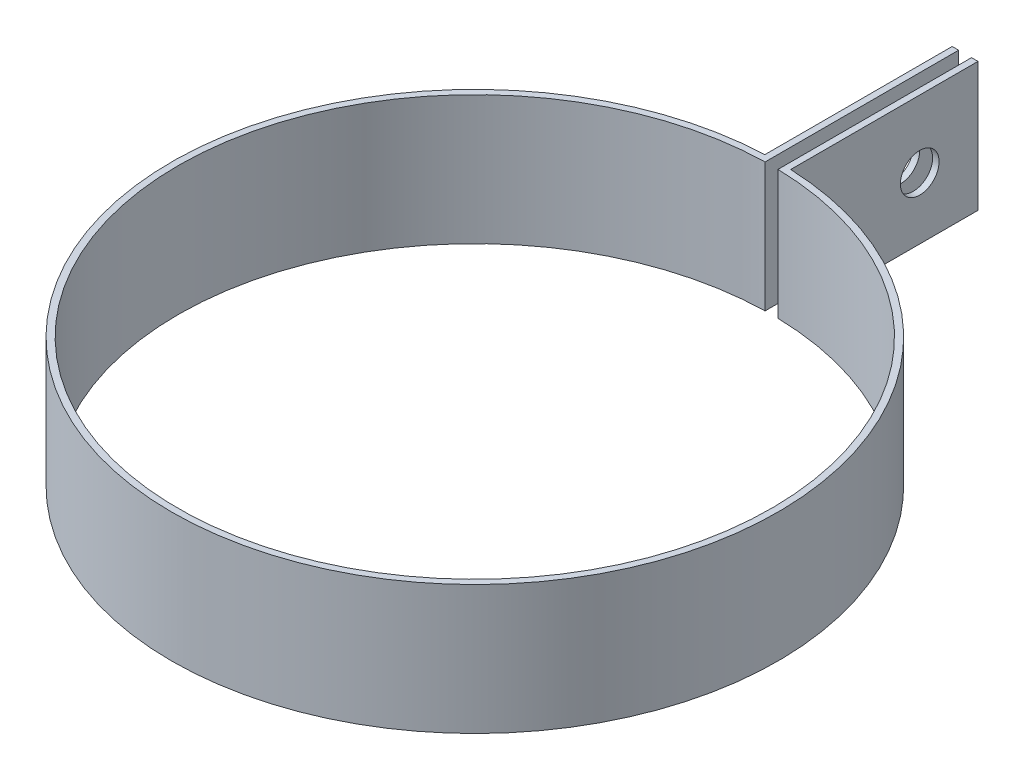
from build123d import *

# Parameters (mm, degrees)
BOSS_EXTRUDE1_DEPTH = 10
SKETCH2_R           = 1.5
CUT_EXTRUDE1_DEPTH  = 25.5


with BuildPart() as part:
    # Sketch1 → Boss-Extrude1 (new body)
    with BuildSketch(Plane(origin=(0, 0, 0), x_dir=(1, 0, 0), z_dir=(0, 1, 0))):
        with BuildLine():
            Line((-0.5, 37.994564575), (-0.5, 22.994564575))
            ThreePointArc((-0.5, 22.994564575), (0, -23), (0.5, 22.994564575))
            Line((0.5, 22.994564575), (0.5, 37.994564575))
            Line((0.5, 37.994564575), (1, 37.994564575))
            Line((1, 37.994564575), (1, 23.478713764))
            ThreePointArc((1, 23.478713764), (0, -23.5), (-1, 23.478713764))
            Line((-1, 23.478713764), (-1, 37.994564575))
            Line((-1, 37.994564575), (-0.5, 37.994564575))
        make_face()
    extrude(amount=BOSS_EXTRUDE1_DEPTH)

    # Sketch2 → Cut-Extrude1 (cut, through all)
    with BuildSketch(Plane(origin=(1, 0, 0), x_dir=(0, 0, -1), z_dir=(1, 0, 0))):
        with Locations((33.478713764, 4.782975317)):
            Circle(SKETCH2_R)
    extrude(amount=-CUT_EXTRUDE1_DEPTH, mode=Mode.SUBTRACT)


solid = part.part
